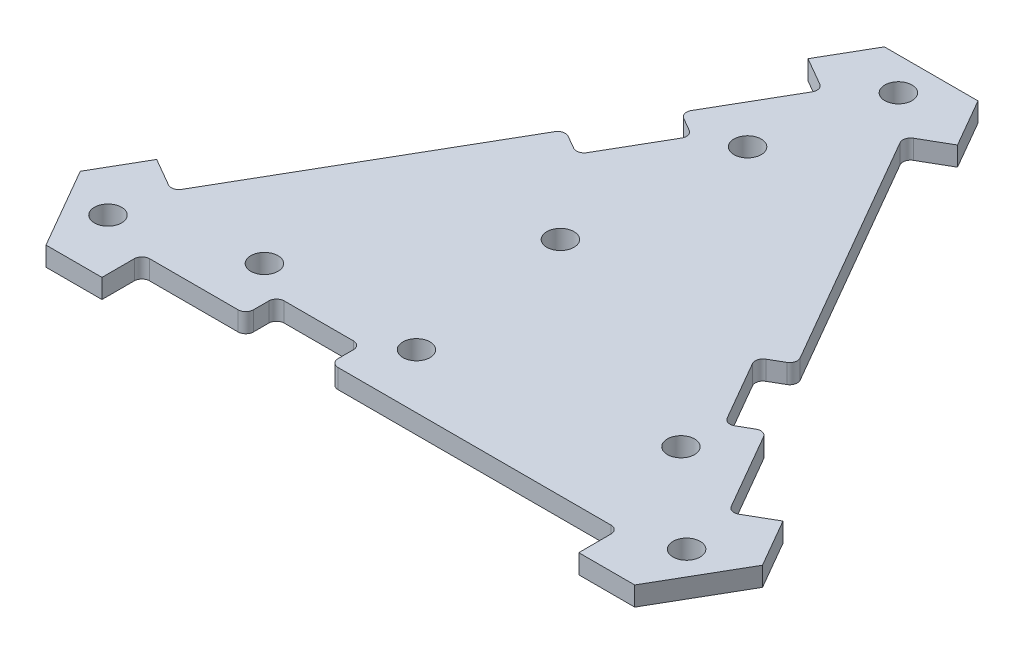
from build123d import *

# Parameters (mm, degrees)
BOSS_EXTRUDE1_DEPTH      = 3.175
SKETCH2_W                = 78.74
SKETCH2_H                = 6.604
CUT_EXTRUDE1_DEPTH       = 83.797133034
SKETCH8_W                = 13.97
SKETCH8_H                = 5.08
CUT_EXTRUDE2_DEPTH       = 83.797133034
FILLET1_R                = 1.27
F_8_CLEARANCE_HOLE1_D    = 4.4958
CIRPATTERN1_COUNT        = 3
FILLET1_OF_CIRPATTERN1_R = 1.27
F_8_CLEARANCE_HOLE2_D    = 4.4958
CIRPATTERN2_COUNT        = 3
F_8_CLEARANCE_HOLE3_D    = 4.4958


with BuildPart() as part:
    # Sketch1 → Boss-Extrude1 (new body)
    with BuildSketch(Plane(origin=(0, 0, 0), x_dir=(1, 0, 0), z_dir=(0, 1, 0))):
        Polygon((48.611580185, -36.986616861), (56.337139895, -23.605554928), (7.725559709, 60.592171789), (-7.725559709, 60.592171789), (-56.337139895, -23.605554928), (-48.611580185, -36.986616861), align=None)
    extrude(amount=-BOSS_EXTRUDE1_DEPTH)

    # Sketch2 → Cut-Extrude1 (cut, through all)
    with BuildSketch(Plane(origin=(0, 0, 0), x_dir=(1, 0, 0), z_dir=(0, 1, 0))):
        with Locations((0, -33.684616861)):
            Rectangle(SKETCH2_W, SKETCH2_H)
    cut_extrude1 = extrude(amount=-CUT_EXTRUDE1_DEPTH, mode=Mode.SUBTRACT)

    # Sketch8 → Cut-Extrude2 (cut, through all)
    with BuildSketch(Plane(origin=(0, 0, 0), x_dir=(1, 0, 0), z_dir=(0, 1, 0))):
        with Locations((-15.24, -27.842616861)):
            Rectangle(SKETCH8_W, SKETCH8_H)
    cut_extrude2 = extrude(amount=-CUT_EXTRUDE2_DEPTH, mode=Mode.SUBTRACT)

    # Fillet1
    fillet1_edges = [part.edges().sort_by_distance(p)[0] for p in [
        (-39.37, -1.5875, 30.382616861),
        (39.37, -1.5875, 30.382616861),
        (-8.255, -1.5875, 25.302616861),
        (-22.225, -1.5875, 25.302616861),
        (-8.255, -1.5875, 30.382616861),
        (-22.225, -1.5875, 30.382616861),
    ]]
    fillet(fillet1_edges, radius=FILLET1_R)

    # 8 Clearance Hole1 (through all)
    with Locations(Plane(origin=(0, 0, 0), x_dir=(1, 0, 0), z_dir=(0, 1, 0))):
        with Locations((-47.780246463, -27.585938157)):
            f_8_clearance_hole1 = Hole(F_8_CLEARANCE_HOLE1_D / 2)

    # CirPattern1: Cut-Extrude1, Cut-Extrude2, 8 Clearance Hole1 ×3 about axis
    cirpattern1_axis = Axis((0, 0.15875, 0), (0, -1, 0))
    add([cut_extrude1.rotate(cirpattern1_axis, i * 360 / CIRPATTERN1_COUNT) for i in range(1, CIRPATTERN1_COUNT)], mode=Mode.SUBTRACT)
    add([cut_extrude2.rotate(cirpattern1_axis, i * 360 / CIRPATTERN1_COUNT) for i in range(1, CIRPATTERN1_COUNT)], mode=Mode.SUBTRACT)
    add([f_8_clearance_hole1.rotate(cirpattern1_axis, i * 360 / CIRPATTERN1_COUNT) for i in range(1, CIRPATTERN1_COUNT)], mode=Mode.SUBTRACT)

    # Fillet1 of CirPattern1
    fillet1_of_cirpattern1_edges = [part.edges().sort_by_distance(p)[0] for p in [
        (-6.627118036, -1.5875, -49.286728578),
        (-45.997118036, -1.5875, 18.904111716),
        (-17.785208984, -1.5875, -19.800348139),
        (-10.800208984, -1.5875, -31.89872303),
        (-22.184618036, -1.5875, -22.340348139),
        (-15.199618036, -1.5875, -34.43872303),
        (45.997118036, -1.5875, 18.904111716),
        (6.627118036, -1.5875, -49.286728578),
        (26.040208984, -1.5875, -5.502268723),
        (33.025208984, -1.5875, 6.596106168),
        (30.439618036, -1.5875, -8.042268723),
        (37.424618036, -1.5875, 4.056106168),
    ]]
    fillet(fillet1_of_cirpattern1_edges, radius=FILLET1_OF_CIRPATTERN1_R)

    # 8 Clearance Hole2 (through all)
    with Locations(Plane(origin=(0, 0, 0), x_dir=(1, 0, 0), z_dir=(0, 1, 0))):
        with Locations((-27.94, -21.59)):
            f_8_clearance_hole2 = Hole(F_8_CLEARANCE_HOLE2_D / 2)

    # CirPattern2: 8 Clearance Hole2 ×3 about axis
    cirpattern2_axis = Axis((0, 8.034658337, 0), (0, -1, 0))
    for i in range(1, CIRPATTERN2_COUNT):
        add(f_8_clearance_hole2.rotate(cirpattern2_axis, i * 360 / CIRPATTERN2_COUNT), mode=Mode.SUBTRACT)

    # 8 Clearance Hole3 (through all)
    with Locations(Plane(origin=(0, 0, 0), x_dir=(1, 0, 0), z_dir=(0, 1, 0))):
        with Locations((-6.934384891, 6.286512516), (-3.048, -21.365616861)):
            Hole(F_8_CLEARANCE_HOLE3_D / 2)


solid = part.part
